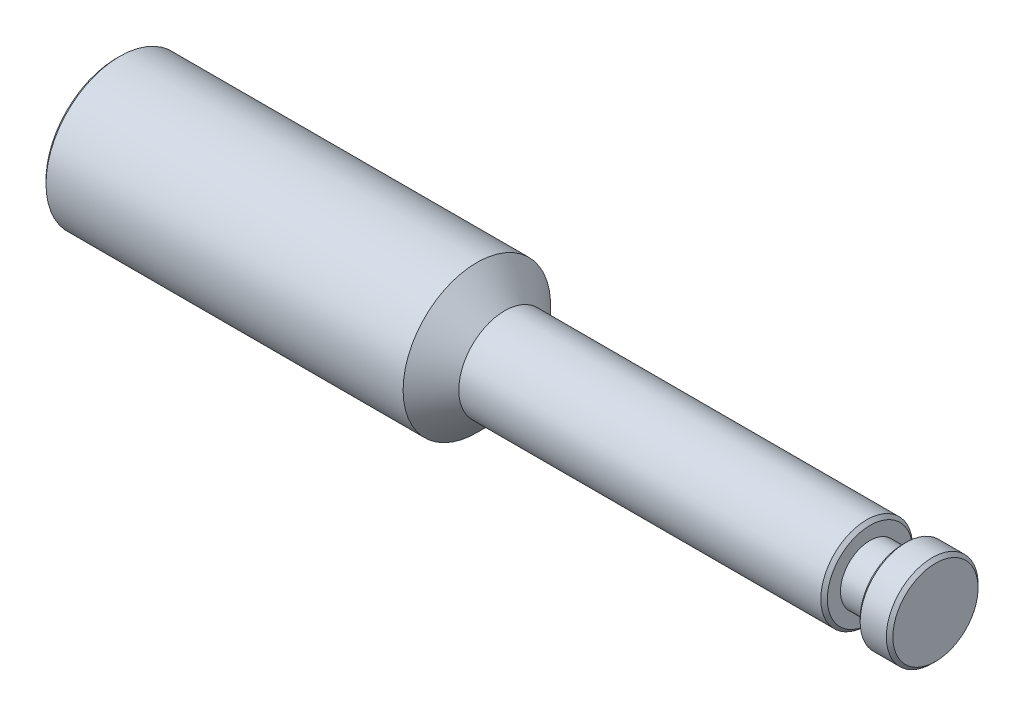
from build123d import *

# Parameters (mm, degrees)
SKETCH2_W     = 10
SKETCH2_H     = 5
CHAMFER1_SIZE = 1


with BuildPart() as part:
    # Sketch1 → Revolve1 (revolve)
    with BuildSketch(Plane.XY):
        Polygon((0, 0), (0, 22.5), (110, 22.5), (118.5, 14), (250, 14), (250, 0), align=None)
    revolve(axis=Axis((0, 0, 0), (1, 0, 0)))

    # Sketch2 → Cut-Revolve1 (revolve, cut)
    with BuildSketch(Plane.XY):
        with Locations((235, 11.5)):
            Rectangle(SKETCH2_W, SKETCH2_H)
    revolve(axis=Axis((0, 0, 0), (1, 0, 0)), mode=Mode.SUBTRACT)

    # Chamfer1
    chamfer1_edges = [part.edges().sort_by_distance(p)[0] for p in [
        (230, -14, 0),
        (240, -14, 0),
        (250, -14, 0),
        (0, -22.5, 0),
    ]]
    chamfer(chamfer1_edges, length=CHAMFER1_SIZE)


solid = part.part
